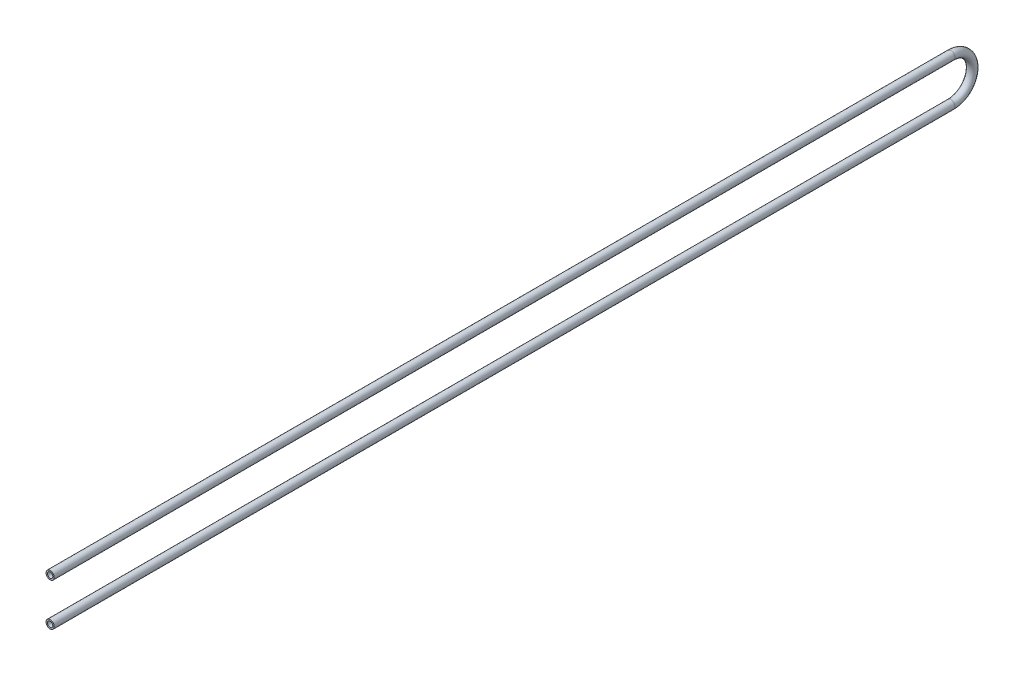
from build123d import *

# Parameters (mm, degrees)
SKETCH2_R   = 10.65
SKETCH2_R_2 = 6.92


with BuildPart() as part:
    # Sweep1: sweep along a path in Sketch1
    with BuildLine(Plane(origin=(0, 0, 0), x_dir=(0, 0, -1), z_dir=(1, 0, 0))) as sweep1_path:
        Line((0, 55), (2325, 55))
        ThreePointArc((2325, 55), (2380, 0), (2325, -55))
        Line((2325, -55), (0, -55))
    # Sketch2 → Sweep1 (sweep)
    with BuildSketch(Plane.XY):
        with Locations((0, 55)):
            Circle(SKETCH2_R)
        with Locations((0, 55)):
            Circle(SKETCH2_R_2, mode=Mode.SUBTRACT)
    sweep(path=sweep1_path.line)


solid = part.part
